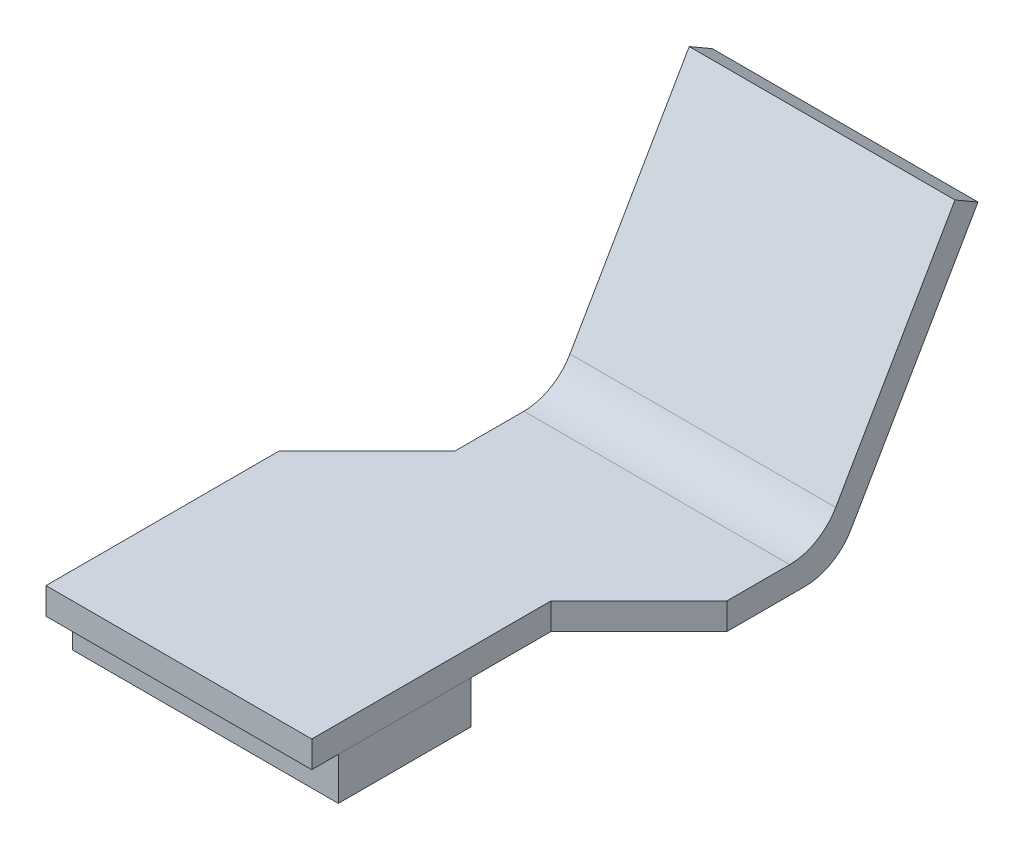
from build123d import *

# Parameters (mm, degrees)
BOSS_EXTRUDE1_DEPTH     = 13.31
CUT_EXTRUDE1_DEPTH      = 1
FILLET1_R               = 2
SKETCH4_W               = 10
SKETCH4_H               = 5
BOSS_EXTRUDE2_DEPTH     = 1.6
CUT_EXTRUDE2_DEPTH      = 10.773313421
CUT_EXTRUDE2_DEPTH_BACK = 2.6


with BuildPart() as part:
    # Sketch1 → Boss-Extrude1 (new body)
    with BuildSketch(Plane(origin=(0, 0, 0), x_dir=(0, 0, -1), z_dir=(1, 0, 0))):
        Polygon((4.487924596, 9.773313421), (-0.577350269, 1), (-16.4065524, 1), (-16.4065524, 0), (0, 0), (5.35395, 9.273313421), align=None)
    extrude(amount=BOSS_EXTRUDE1_DEPTH)

    # Sketch2 → Cut-Extrude1 (cut)
    with BuildSketch(Plane(origin=(0, 0, 0), x_dir=(1, 0, 0), z_dir=(0, 1, 0))):
        Polygon((13.31, -16.4065524), (10, -16.4065524), (10, -7.4065524), (13.31, -4.0965524), align=None)
    extrude(amount=CUT_EXTRUDE1_DEPTH, mode=Mode.SUBTRACT)

    # Fillet1
    fillet1_edges = [part.edges().sort_by_distance(p)[0] for p in [
        (6.655, 0, 0),
        (6.655, 1, 0.577350269),
    ]]
    fillet(fillet1_edges, radius=FILLET1_R)

    # Sketch5 → Cut-Extrude2 (cut, two sides)
    with BuildSketch(Plane(origin=(0, 0, 0), x_dir=(1, 0, 0), z_dir=(0, 1, 0))) as cut_extrude2_sk:
        Polygon((0, 5.35395), (0, -7.64605), (3.31, -4.33605), (3.31, 5.35395), align=None)
    extrude(amount=CUT_EXTRUDE2_DEPTH, mode=Mode.SUBTRACT)
    extrude(cut_extrude2_sk.sketch, amount=-CUT_EXTRUDE2_DEPTH_BACK, mode=Mode.SUBTRACT)


with BuildPart() as body_2:
    # Sketch4 → Boss-Extrude2 (new body)
    with BuildSketch(Plane.XZ):
        with Locations((5, 12.9065524)):
            Rectangle(SKETCH4_W, SKETCH4_H)
    extrude(amount=BOSS_EXTRUDE2_DEPTH)


solid = Compound([part.part, body_2.part])
